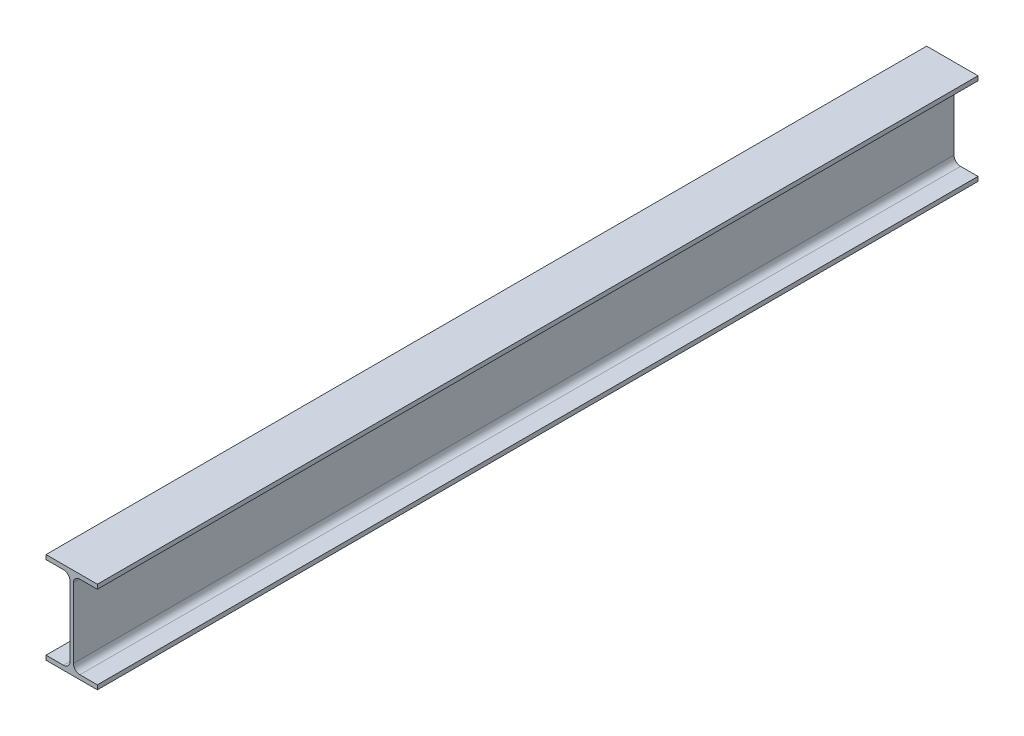
from build123d import *

# Parameters (mm, degrees)
BOSS_EXTRUDE1_DEPTH = 943


with BuildPart() as part:
    # Sketch1 → Boss-Extrude1 (new body)
    with BuildSketch(Plane.XY):
        with BuildLine():
            Line((-27.5, 49), (27.5, 49))
            Line((27.5, 49), (27.5, 44.3))
            Line((27.5, 44.3), (8.8, 44.3))
            ThreePointArc((8.8, 44.3), (3.850252532, 42.249747468), (1.8, 37.3))
            Line((1.8, 37.3), (1.8, -37.3))
            ThreePointArc((1.8, -37.3), (3.850252532, -42.249747468), (8.8, -44.3))
            Line((8.8, -44.3), (27.5, -44.3))
            Line((27.5, -44.3), (27.5, -49))
            Line((27.5, -49), (-27.5, -49))
            Line((-27.5, -49), (-27.5, -44.3))
            Line((-27.5, -44.3), (-8.8, -44.3))
            ThreePointArc((-8.8, -44.3), (-3.850252532, -42.249747468), (-1.8, -37.3))
            Line((-1.8, -37.3), (-1.8, 37.3))
            ThreePointArc((-1.8, 37.3), (-3.850252532, 42.249747468), (-8.8, 44.3))
            Line((-8.8, 44.3), (-27.5, 44.3))
            Line((-27.5, 44.3), (-27.5, 49))
        make_face()
    extrude(amount=BOSS_EXTRUDE1_DEPTH)


solid = part.part
